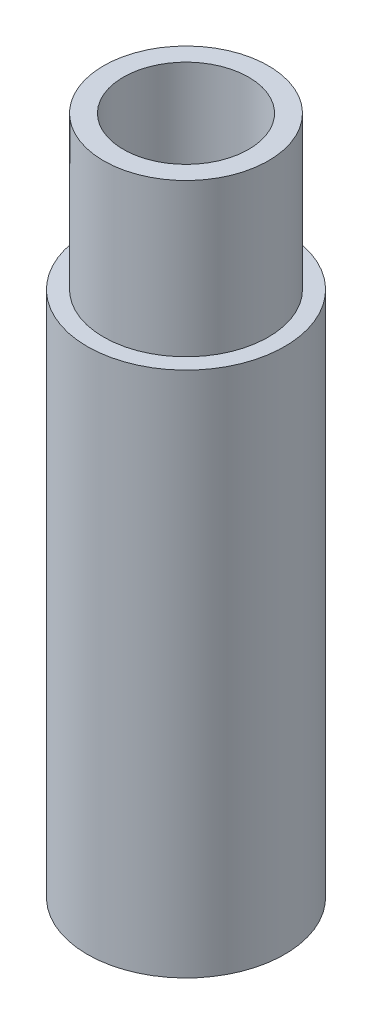
from build123d import *

# Parameters (mm, degrees)
SKETCH1_R                    = 4.7625
BOSS_EXTRUDE1_DEPTH          = 25.4
SKETCH2_R                    = 3.9751
BOSS_EXTRUDE2_DEPTH          = 7.366
SKETCH3_R                    = 3.0226
CUT_EXTRUDE1_DEPTH           = 33.766
F_5_16_24_TAPPED_HOLE1_D     = 6.9088
F_5_16_24_TAPPED_HOLE1_DEPTH = 12.7
F_5_16_24_TAPPED_HOLE1_TIP   = 2.075612922


with BuildPart() as part:
    # Sketch1 → Boss-Extrude1 (new body)
    with BuildSketch(Plane(origin=(0, 0, 0), x_dir=(1, 0, 0), z_dir=(0, 1, 0))):
        with Locations(Location((0, 0, 0), (0, 0, 270))):  # turned: the seam where the file's is
            Circle(SKETCH1_R)
    extrude(amount=BOSS_EXTRUDE1_DEPTH)

    # Sketch2 → Boss-Extrude2 (add)
    with BuildSketch(Plane(origin=(0, 25.4, 0), x_dir=(1, 0, 0), z_dir=(0, 1, 0))):
        with Locations(Location((0, 0, 0), (0, 0, 270))):  # turned: the seam where the file's is
            Circle(SKETCH2_R)
    extrude(amount=BOSS_EXTRUDE2_DEPTH)

    # Sketch3 → Cut-Extrude1 (cut, through all)
    with BuildSketch(Plane.XZ):
        with Locations(Location((0, 0, 0), (0, 0, 270))):  # turned: the seam where the file's is
            Circle(SKETCH3_R)
    extrude(amount=-CUT_EXTRUDE1_DEPTH, mode=Mode.SUBTRACT)

    # 5/16-24 Tapped Hole1
    with Locations(Plane(origin=(0, 0, 0), x_dir=(-1, 0, 0), z_dir=(0, -1, 0))):
        with Locations((0, 0)):
            Hole(F_5_16_24_TAPPED_HOLE1_D / 2, depth=F_5_16_24_TAPPED_HOLE1_DEPTH)
            with Locations((0, 0, -(F_5_16_24_TAPPED_HOLE1_DEPTH + F_5_16_24_TAPPED_HOLE1_TIP / 2))):  # 118° drill point
                Cone(0, F_5_16_24_TAPPED_HOLE1_D / 2, F_5_16_24_TAPPED_HOLE1_TIP, mode=Mode.SUBTRACT)


solid = part.part
